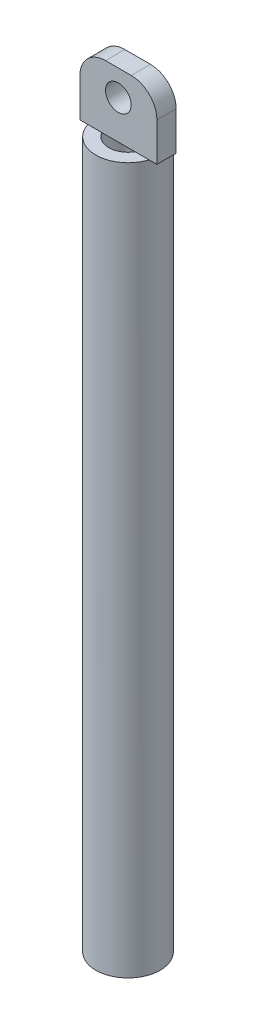
from build123d import *

# Parameters (mm, degrees)
SKETCH1_R           = 2.5
SKETCH1_R_2         = 1.5
BOSS_EXTRUDE1_DEPTH = 55
SKETCH2_W           = 6
SKETCH2_H           = 1.5
BOSS_EXTRUDE2_DEPTH = 5
SKETCH3_R           = 1
CUT_EXTRUDE1_DEPTH  = 4.25
FILLET1_R           = 2


with BuildPart() as part:
    # Sketch1 → Boss-Extrude1 (new body)
    with BuildSketch(Plane(origin=(0, 0, 0), x_dir=(1, 0, 0), z_dir=(0, 1, 0))):
        Circle(SKETCH1_R)
        Circle(SKETCH1_R_2, mode=Mode.SUBTRACT)
    extrude(amount=BOSS_EXTRUDE1_DEPTH)

    # Sketch2 → Boss-Extrude2 (add)
    with BuildSketch(Plane(origin=(0, 55, 0), x_dir=(1, 0, 0), z_dir=(0, 1, 0))):
        Rectangle(SKETCH2_W, SKETCH2_H)
    extrude(amount=BOSS_EXTRUDE2_DEPTH)

    # Sketch3 → Cut-Extrude1 (cut, through all)
    with BuildSketch(Plane(origin=(0, 0, -0.75), x_dir=(-1, 0, 0), z_dir=(0, 0, -1))):
        with Locations((0, 58)):
            Circle(SKETCH3_R)
    extrude(amount=-CUT_EXTRUDE1_DEPTH, mode=Mode.SUBTRACT)

    # Fillet1
    fillet1_edges = [part.edges().sort_by_distance(p)[0] for p in [
        (3, 60, 0),
        (-3, 60, 0),
    ]]
    fillet(fillet1_edges, radius=FILLET1_R)


solid = part.part
